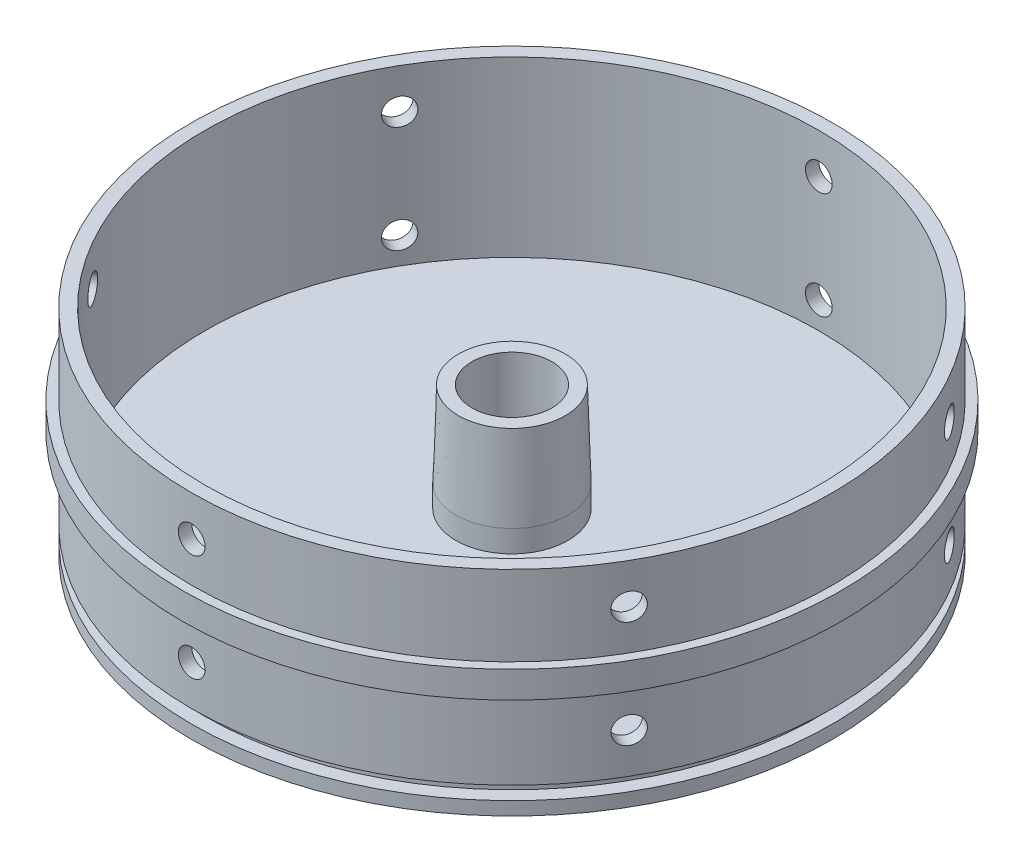
from build123d import *

# Parameters (mm, degrees)
SKETCH1_R           = 78.359
SKETCH1_R_2         = 76.2
BOSS_EXTRUDE1_DEPTH = 6.35
SKETCH1_3_R         = 76.2
SKETCH1_3_R_2       = 73.025
BOSS_EXTRUDE2_DEPTH = 25.4
BOSS_EXTRUDE3_START = 25.4
SKETCH2_R           = 76.2
SKETCH2_R_2         = 73.025
BOSS_EXTRUDE3_DEPTH = 25.4
SKETCH3_R           = 76.2
BOSS_EXTRUDE4_DEPTH = 9.525
SKETCH5_W           = 3.175
SKETCH5_H           = 3.175
SKETCH6_R           = 3.175
CUT_EXTRUDE1_DEPTH  = 12.7
CIRPATTERN1_COUNT   = 6
SKETCH7_R           = 13.335
SKETCH7_R_2         = 9.525
BOSS_EXTRUDE5_DEPTH = 25.4
SKETCH7_3_R         = 9.525
CUT_EXTRUDE2_DEPTH  = 119.253504791
CHAMFER1_SIZE       = 20.16
CHAMFER1_SIZE2      = 0.629996264


with BuildPart() as part:
    # Sketch1 → Boss-Extrude1 (new body)
    with BuildSketch(Plane(origin=(0, 0, 0), x_dir=(1, 0, 0), z_dir=(0, 1, 0))):
        Circle(SKETCH1_R)
        Circle(SKETCH1_R_2, mode=Mode.SUBTRACT)
    extrude(amount=BOSS_EXTRUDE1_DEPTH)

    # Sketch1_3 → Boss-Extrude2 (add)
    with BuildSketch(Plane(origin=(0, 0, 0), x_dir=(1, 0, 0), z_dir=(0, 1, 0))):
        Circle(SKETCH1_3_R)
        Circle(SKETCH1_3_R_2, mode=Mode.SUBTRACT)
    extrude(amount=BOSS_EXTRUDE2_DEPTH)

    # Sketch2 → Boss-Extrude3 (add)
    with BuildSketch(Plane.XZ.offset(BOSS_EXTRUDE3_START)):
        Circle(SKETCH2_R)
        Circle(SKETCH2_R_2, mode=Mode.SUBTRACT)
    extrude(amount=-BOSS_EXTRUDE3_DEPTH)

    # Sketch3 → Boss-Extrude4 (add)
    with BuildSketch(Plane.XZ.offset(25.4)):
        Circle(SKETCH3_R)
    extrude(amount=-BOSS_EXTRUDE4_DEPTH)

    # Sketch5 → Cut-Revolve1 (revolve, cut)
    with BuildSketch(Plane.XY):
        with Locations((-74.6125, -20.6375)):
            Rectangle(SKETCH5_W, SKETCH5_H)
    revolve(axis=Axis((0, 0, 0), (0, -1, 0)), mode=Mode.SUBTRACT)

    # Sketch6 → Cut-Extrude1 (cut)
    with BuildSketch(Plane.XY.offset(76.2)):
        with Locations((0, 15.875)):
            Circle(SKETCH6_R)
        with Locations((0, -9.525)):
            Circle(SKETCH6_R)
    cut_extrude1 = extrude(amount=-CUT_EXTRUDE1_DEPTH, mode=Mode.SUBTRACT)

    # CirPattern1: Cut-Extrude1 ×6 about axis
    cirpattern1_axis = Axis((0, 25.4, 0), (0, -1, 0))
    for i in range(1, CIRPATTERN1_COUNT):
        add(cut_extrude1.rotate(cirpattern1_axis, i * 360 / CIRPATTERN1_COUNT), mode=Mode.SUBTRACT)

    # Sketch7 → Boss-Extrude5 (add)
    with BuildSketch(Plane(origin=(0, -15.875, 0), x_dir=(1, 0, 0), z_dir=(0, 1, 0))):
        Circle(SKETCH7_R)
        Circle(SKETCH7_R_2, mode=Mode.SUBTRACT)
    extrude(amount=BOSS_EXTRUDE5_DEPTH)

    # Sketch7_3 → Cut-Extrude2 (cut, through all)
    with BuildSketch(Plane(origin=(0, -15.875, 0), x_dir=(1, 0, 0), z_dir=(0, 1, 0))):
        Circle(SKETCH7_3_R)
    extrude(amount=-CUT_EXTRUDE2_DEPTH, mode=Mode.SUBTRACT)

    # Chamfer1
    chamfer1_edges = [part.edges().sort_by_distance(p)[0] for p in [
        (-13.335, 9.525, 0),
    ]]
    chamfer1_side = [part.faces().sort_by_distance(p)[0] for p in [
        (-13.335, -3.175, 0),
    ]]
    chamfer(chamfer1_edges, length=CHAMFER1_SIZE, length2=CHAMFER1_SIZE2, reference=chamfer1_side[0])


solid = part.part
